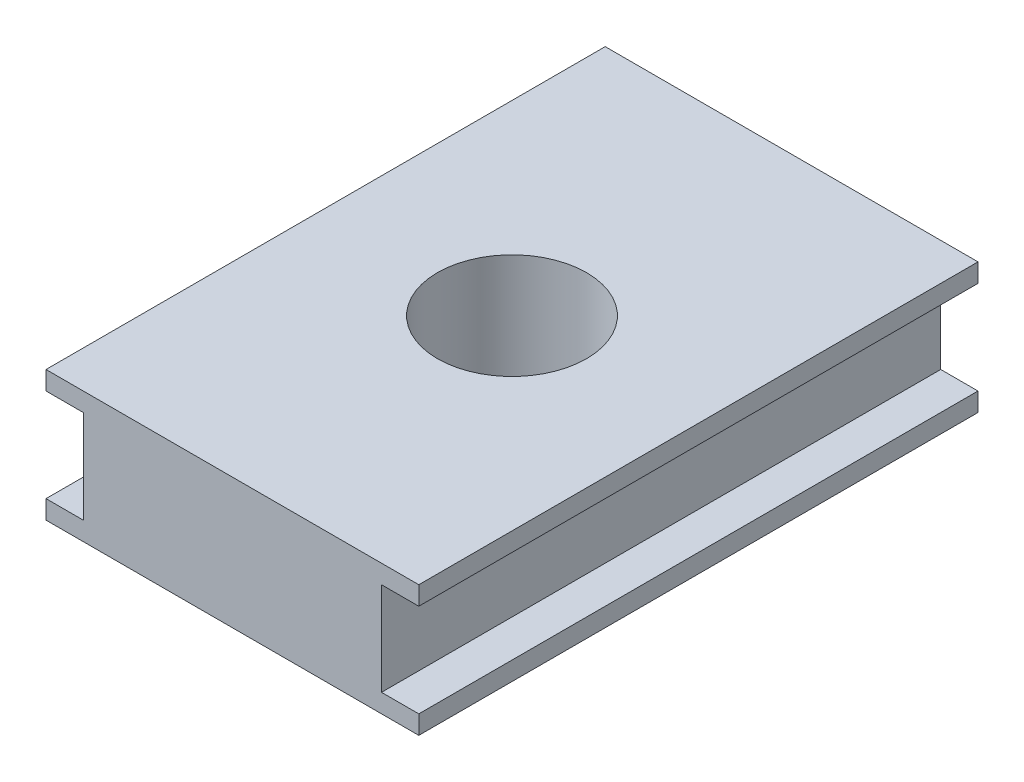
from build123d import *

# Parameters (mm, degrees)
SKETCH1_W           = 20
SKETCH1_H           = 30
BOSS_EXTRUDE1_DEPTH = 7
SKETCH2_W           = 30
SKETCH2_H           = 5
CUT_EXTRUDE1_DEPTH  = 2
SKETCH3_W           = 30
SKETCH3_H           = 5
CUT_EXTRUDE2_DEPTH  = 2
SKETCH4_R           = 4
CUT_EXTRUDE3_DEPTH  = 10


with BuildPart() as part:
    # Sketch1 → Boss-Extrude1 (new body)
    with BuildSketch(Plane(origin=(0, 0, 0), x_dir=(1, 0, 0), z_dir=(0, 1, 0))):
        Rectangle(SKETCH1_W, SKETCH1_H)
    extrude(amount=BOSS_EXTRUDE1_DEPTH)

    # Sketch2 → Cut-Extrude1 (cut)
    with BuildSketch(Plane(origin=(10, 0, 0), x_dir=(0, 0, -1), z_dir=(1, 0, 0))):
        with Locations((0, 3.5)):
            Rectangle(SKETCH2_W, SKETCH2_H)
    extrude(amount=-CUT_EXTRUDE1_DEPTH, mode=Mode.SUBTRACT)

    # Sketch3 → Cut-Extrude2 (cut)
    with BuildSketch(Plane.ZY.offset(10)):
        with Locations((0, 3.5)):
            Rectangle(SKETCH3_W, SKETCH3_H)
    extrude(amount=-CUT_EXTRUDE2_DEPTH, mode=Mode.SUBTRACT)

    # Sketch4 → Cut-Extrude3 (cut)
    with BuildSketch(Plane(origin=(0, 7, 0), x_dir=(1, 0, 0), z_dir=(0, 1, 0))):
        Circle(SKETCH4_R)
    extrude(amount=-CUT_EXTRUDE3_DEPTH, mode=Mode.SUBTRACT)


solid = part.part
